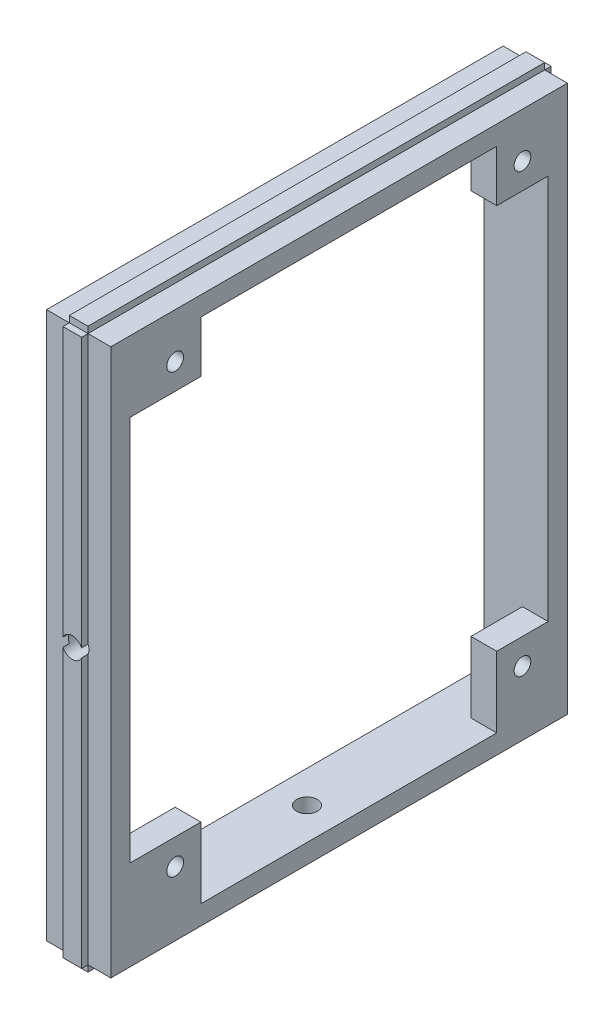
from build123d import *

# Parameters (mm, degrees)
MAIN_DEPTH           = 71
SKETCH2_W            = 2.9
SKETCH2_H            = 85
MAKERBEAMRAIL1_DEPTH = 1
SKETCH3_W            = 2.9
SKETCH3_H            = 85
MAKERBEAMRAIL2_DEPTH = 1
SKETCH4_W            = 65
SKETCH4_H            = 79
BOARDCUT_DEPTH       = 6
SKETCH5_R            = 1.3
BOARDHOLES_DEPTH     = 5
SKETCH6_R            = 1.6
FIXHOLE1_DEPTH       = 4
MAINHOLE_DEPTH       = 5
FIXHOLE2_REACH       = 89
SKETCH8_R            = 1.6


with BuildPart() as part:
    # Sketch1 → Main (new body)
    with BuildSketch(Plane.XY):
        Polygon((0, 85), (3.55, 85), (3.55, 86), (6.45, 86), (6.45, 85), (10, 85), (10, 0), (6.45, 0), (6.45, -1), (3.55, -1), (3.55, 0), (0, 0), align=None)
    extrude(amount=MAIN_DEPTH)

    # Sketch2 → MakerBeamRail1 (add)
    with BuildSketch(Plane.XY.offset(71)):
        with Locations((5, 42.5)):
            Rectangle(SKETCH2_W, SKETCH2_H)
    extrude(amount=MAKERBEAMRAIL1_DEPTH)

    # Sketch3 → MakerBeamRail2 (add)
    with BuildSketch(Plane(origin=(0, 0, 0), x_dir=(-1, 0, 0), z_dir=(0, 0, -1))):
        with Locations((-5, 42.5)):
            Rectangle(SKETCH3_W, SKETCH3_H)
    extrude(amount=MAKERBEAMRAIL2_DEPTH)

    # Sketch4 → BoardCut (cut)
    with BuildSketch(Plane.ZY):
        with Locations((35.5, 42.5)):
            Rectangle(SKETCH4_W, SKETCH4_H)
    extrude(amount=-BOARDCUT_DEPTH, mode=Mode.SUBTRACT)

    # Sketch5 → BoardHoles (cut, through all)
    with BuildSketch(Plane.ZY.offset(-6)):
        with Locations((7, 78)):
            Circle(SKETCH5_R)
        with Locations((61, 78)):
            Circle(SKETCH5_R)
        with Locations((61, 10)):
            Circle(SKETCH5_R)
        with Locations((7, 10)):
            Circle(SKETCH5_R)
    extrude(amount=-BOARDHOLES_DEPTH, mode=Mode.SUBTRACT)

    # Sketch6 → FixHole1 (cut)
    with BuildSketch(Plane.XY.offset(72)):
        with Locations((5, 42.5)):
            Circle(SKETCH6_R)
    extrude(amount=-FIXHOLE1_DEPTH, mode=Mode.SUBTRACT)

    # Sketch7 → MainHole (cut, through all)
    with BuildSketch(Plane.ZY.offset(-6)):
        Polygon((3, 74), (11, 74), (11, 82), (57, 82), (57, 74), (68, 74), (68, 14), (57, 14), (57, 3), (11, 3), (11, 14), (3, 14), align=None)
    extrude(amount=-MAINHOLE_DEPTH, mode=Mode.SUBTRACT)

    # Sketch8 → FixHole2 (cut, up to next)
    with BuildSketch(Plane(origin=(0, -1, 0), x_dir=(-1, 0, 0), z_dir=(0, -1, 0)), mode=Mode.PRIVATE) as fixhole2_sk1:
        with Locations((-5, -35.5)):
            Circle(SKETCH8_R)
    fixhole2_tool1 = extrude(fixhole2_sk1.sketch, amount=-FIXHOLE2_REACH, mode=Mode.PRIVATE) & part.part
    add(fixhole2_tool1.solids().sort_by_distance((5, -1, 35.5))[0], mode=Mode.SUBTRACT)


solid = part.part
